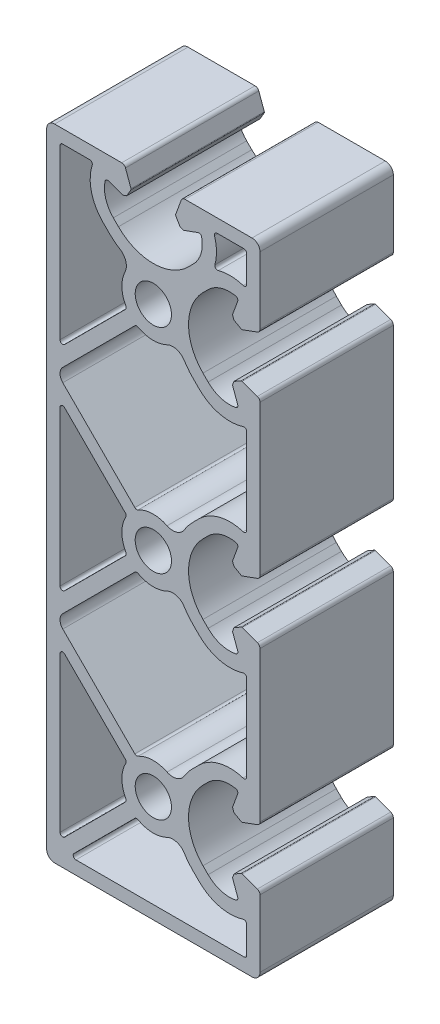
from build123d import *

# Parameters (mm, degrees)
SK_MAIN_EXTRUSION_R  = 3.4
MAIN_EXTRUSION_DEPTH = 25


with BuildPart() as part:
    # Sk Main Extrusion → Main Extrusion (new body)
    with BuildSketch(Plane.XY):
        with BuildLine():
            Line((16.671180212, 4.190076845), (19.506515107, 5.222054351))
            ThreePointArc((19.506515107, 5.222054351), (19.864364033, 5.496641489), (20, 5.926823816))
            Line((20, 5.926823816), (20, 34.073176184))
            ThreePointArc((20, 34.073176184), (19.864364033, 34.503358511), (19.506515107, 34.777945649))
            Line((19.506515107, 34.777945649), (16.671180212, 35.809923155))
            ThreePointArc((16.671180212, 35.809923155), (16.563886241, 35.824048675), (16.460675177, 35.791506351))
            Line((16.460675177, 35.791506351), (15.111296024, 35.012441934))
            Line((15.111296024, 35.012441934), (14.845251581, 34.281490834))
            Line((14.845251581, 34.281490834), (15.81984631, 31.603813821))
            ThreePointArc((15.81984631, 31.603813821), (15.786489799, 31.188925388), (15.450654467, 30.943039849))
            ThreePointArc((15.450654467, 30.943039849), (12.665882372, 31.066566987), (10.272684887, 32.495839661))
            Line((10.272684887, 32.495839661), (9.309262274, 33.459262274))
            ThreePointArc((9.309262274, 33.459262274), (6.6, 40), (9.309262274, 46.540737726))
            Line((9.309262274, 46.540737726), (10.272684887, 47.504160339))
            ThreePointArc((10.272684887, 47.504160339), (12.665882372, 48.933433013), (15.450654467, 49.056960151))
            ThreePointArc((15.450654467, 49.056960151), (15.786489799, 48.811074612), (15.81984631, 48.396186179))
            Line((15.81984631, 48.396186179), (14.845251581, 45.718509166))
            Line((14.845251581, 45.718509166), (15.111296024, 44.987558066))
            Line((15.111296024, 44.987558066), (16.460675177, 44.208493649))
            ThreePointArc((16.460675177, 44.208493649), (16.563886241, 44.175951325), (16.671180212, 44.190076845))
            Line((16.671180212, 44.190076845), (19.506515107, 45.222054351))
            ThreePointArc((19.506515107, 45.222054351), (19.864364033, 45.496641489), (20, 45.926823816))
            Line((20, 45.926823816), (20, 58.5))
            ThreePointArc((20, 58.5), (19.560660172, 59.560660172), (18.5, 60))
            Line((18.5, 60), (5.926823816, 60))
            ThreePointArc((5.926823816, 60), (5.496641489, 59.864364033), (5.222054351, 59.506515107))
            Line((5.222054351, 59.506515107), (4.190076845, 56.671180212))
            ThreePointArc((4.190076845, 56.671180212), (4.175951325, 56.563886241), (4.208493649, 56.460675177))
            Line((4.208493649, 56.460675177), (4.987558066, 55.111296024))
            Line((4.987558066, 55.111296024), (5.718509166, 54.845251581))
            Line((5.718509166, 54.845251581), (8.396186179, 55.81984631))
            ThreePointArc((8.396186179, 55.81984631), (8.811074612, 55.786489799), (9.056960151, 55.450654467))
            ThreePointArc((9.056960151, 55.450654467), (8.933433013, 52.665882372), (7.504160339, 50.272684887))
            Line((7.504160339, 50.272684887), (6.540737726, 49.309262274))
            ThreePointArc((6.540737726, 49.309262274), (0, 46.6), (-6.540737726, 49.309262274))
            Line((-6.540737726, 49.309262274), (-7.504160339, 50.272684887))
            ThreePointArc((-7.504160339, 50.272684887), (-8.933433013, 52.665882372), (-9.056960151, 55.450654467))
            ThreePointArc((-9.056960151, 55.450654467), (-8.811074612, 55.786489799), (-8.396186179, 55.81984631))
            Line((-8.396186179, 55.81984631), (-5.718509166, 54.845251581))
            Line((-5.718509166, 54.845251581), (-4.987558066, 55.111296024))
            Line((-4.987558066, 55.111296024), (-4.208493649, 56.460675177))
            ThreePointArc((-4.208493649, 56.460675177), (-4.175951325, 56.563886241), (-4.190076845, 56.671180212))
            Line((-4.190076845, 56.671180212), (-5.222054351, 59.506515107))
            ThreePointArc((-5.222054351, 59.506515107), (-5.496641489, 59.864364033), (-5.926823816, 60))
            Line((-5.926823816, 60), (-18.5, 60))
            ThreePointArc((-18.5, 60), (-19.560660172, 59.560660172), (-20, 58.5))
            Line((-20, 58.5), (-20, -58.5))
            ThreePointArc((-20, -58.5), (-19.560660172, -59.560660172), (-18.5, -60))
            Line((-18.5, -60), (18.5, -60))
            ThreePointArc((18.5, -60), (19.560660172, -59.560660172), (20, -58.5))
            Line((20, -58.5), (20, -45.926823816))
            ThreePointArc((20, -45.926823816), (19.864364033, -45.496641489), (19.506515107, -45.222054351))
            Line((19.506515107, -45.222054351), (16.671180212, -44.190076845))
            ThreePointArc((16.671180212, -44.190076845), (16.563886241, -44.175951325), (16.460675177, -44.208493649))
            Line((16.460675177, -44.208493649), (15.111296024, -44.987558066))
            Line((15.111296024, -44.987558066), (14.845251581, -45.718509166))
            Line((14.845251581, -45.718509166), (15.81984631, -48.396186179))
            ThreePointArc((15.81984631, -48.396186179), (15.786489799, -48.811074612), (15.450654467, -49.056960151))
            ThreePointArc((15.450654467, -49.056960151), (12.665882372, -48.933433013), (10.272684887, -47.504160339))
            Line((10.272684887, -47.504160339), (9.309262274, -46.540737726))
            ThreePointArc((9.309262274, -46.540737726), (6.6, -40), (9.309262274, -33.459262274))
            Line((9.309262274, -33.459262274), (10.272684887, -32.495839661))
            ThreePointArc((10.272684887, -32.495839661), (12.665882372, -31.066566987), (15.450654467, -30.943039849))
            ThreePointArc((15.450654467, -30.943039849), (15.786489799, -31.188925388), (15.81984631, -31.603813821))
            Line((15.81984631, -31.603813821), (14.845251581, -34.281490834))
            Line((14.845251581, -34.281490834), (15.111296024, -35.012441934))
            Line((15.111296024, -35.012441934), (16.460675177, -35.791506351))
            ThreePointArc((16.460675177, -35.791506351), (16.563886241, -35.824048675), (16.671180212, -35.809923155))
            Line((16.671180212, -35.809923155), (19.506515107, -34.777945649))
            ThreePointArc((19.506515107, -34.777945649), (19.864364033, -34.503358511), (20, -34.073176184))
            Line((20, -34.073176184), (20, -5.926823816))
            ThreePointArc((20, -5.926823816), (19.864364033, -5.496641489), (19.506515107, -5.222054351))
            Line((19.506515107, -5.222054351), (16.671180212, -4.190076845))
            ThreePointArc((16.671180212, -4.190076845), (16.563886241, -4.175951325), (16.460675177, -4.208493649))
            Line((16.460675177, -4.208493649), (15.111296024, -4.987558066))
            Line((15.111296024, -4.987558066), (14.845251581, -5.718509166))
            Line((14.845251581, -5.718509166), (15.81984631, -8.396186179))
            ThreePointArc((15.81984631, -8.396186179), (15.786489799, -8.811074612), (15.450654467, -9.056960151))
            ThreePointArc((15.450654467, -9.056960151), (12.665882372, -8.933433013), (10.272684887, -7.504160339))
            Line((10.272684887, -7.504160339), (9.309262274, -6.540737726))
            ThreePointArc((9.309262274, -6.540737726), (6.6, 0), (9.309262274, 6.540737726))
            Line((9.309262274, 6.540737726), (10.272684887, 7.504160339))
            ThreePointArc((10.272684887, 7.504160339), (12.665882372, 8.933433013), (15.450654467, 9.056960151))
            ThreePointArc((15.450654467, 9.056960151), (15.786489799, 8.811074612), (15.81984631, 8.396186179))
            Line((15.81984631, 8.396186179), (14.845251581, 5.718509166))
            Line((14.845251581, 5.718509166), (15.111296024, 4.987558066))
            Line((15.111296024, 4.987558066), (16.460675177, 4.208493649))
            ThreePointArc((16.460675177, 4.208493649), (16.563886241, 4.175951325), (16.671180212, 4.190076845))
        make_face()
        with Locations((0, -40)):
            Circle(SK_MAIN_EXTRUSION_R, mode=Mode.SUBTRACT)
        with Locations((0, 40)):
            Circle(SK_MAIN_EXTRUSION_R, mode=Mode.SUBTRACT)
        Circle(SK_MAIN_EXTRUSION_R, mode=Mode.SUBTRACT)
        with BuildLine():
            Line((-17.5, 57), (-17.5, 25.474873734))
            ThreePointArc((-17.5, 25.474873734), (-17.191341716, 25.012933968), (-16.646446609, 25.121320344))
            Line((-16.646446609, 25.121320344), (-5.236899672, 36.530867281))
            ThreePointArc((-5.236899672, 36.530867281), (-5.095239754, 36.81540054), (-5.153698917, 37.127825306))
            ThreePointArc((-5.153698917, 37.127825306), (-5.897648575, 39.833442852), (-5.307583096, 42.576734694))
            ThreePointArc((-5.307583096, 42.576734694), (-5.153883821, 44.359333373), (-6.230846881, 45.788120301))
            ThreePointArc((-6.230846881, 45.788120301), (-7.316529108, 46.555931161), (-8.308504679, 47.441495321))
            Line((-8.308504679, 47.441495321), (-9.444282589, 48.577273231))
            ThreePointArc((-9.444282589, 48.577273231), (-11.611987193, 52.430514315), (-11.464011904, 56.849169473))
            ThreePointArc((-11.464011904, 56.849169473), (-11.537349181, 57.295452819), (-11.940719521, 57.5))
            Line((-11.940719521, 57.5), (-17, 57.5))
            ThreePointArc((-17, 57.5), (-17.353553391, 57.353553391), (-17.5, 57))
        make_face(mode=Mode.SUBTRACT)
        with BuildLine():
            Line((-3.469132719, 34.763100328), (-16.982233047, 21.25))
            ThreePointArc((-16.982233047, 21.25), (-17.5, 20), (-16.982233047, 18.75))
            Line((-16.982233047, 18.75), (-3.469132719, 5.236899672))
            ThreePointArc((-3.469132719, 5.236899672), (-3.18459946, 5.095239754), (-2.872174694, 5.153698917))
            ThreePointArc((-2.872174694, 5.153698917), (-0.166557148, 5.897648575), (2.576734694, 5.307583096))
            ThreePointArc((2.576734694, 5.307583096), (4.359333373, 5.153883821), (5.788120301, 6.230846881))
            ThreePointArc((5.788120301, 6.230846881), (6.555931161, 7.316529108), (7.441495321, 8.308504679))
            Line((7.441495321, 8.308504679), (8.577273231, 9.444282589))
            ThreePointArc((8.577273231, 9.444282589), (12.430514315, 11.611987193), (16.849169473, 11.464011904))
            ThreePointArc((16.849169473, 11.464011904), (17.295452819, 11.537349181), (17.5, 11.940719521))
            Line((17.5, 11.940719521), (17.5, 28.059280479))
            ThreePointArc((17.5, 28.059280479), (17.295452819, 28.462650819), (16.849169473, 28.535988096))
            ThreePointArc((16.849169473, 28.535988096), (12.430514315, 28.388012807), (8.577273231, 30.555717411))
            Line((8.577273231, 30.555717411), (7.441495321, 31.691495321))
            ThreePointArc((7.441495321, 31.691495321), (6.555931161, 32.683470892), (5.788120301, 33.769153119))
            ThreePointArc((5.788120301, 33.769153119), (4.359333373, 34.846116179), (2.576734694, 34.692416904))
            ThreePointArc((2.576734694, 34.692416904), (-0.166557148, 34.102351425), (-2.872174694, 34.846301083))
            ThreePointArc((-2.872174694, 34.846301083), (-3.18459946, 34.904760246), (-3.469132719, 34.763100328))
        make_face(mode=Mode.SUBTRACT)
        with BuildLine():
            Line((-17.5, 14.525126266), (-17.5, -14.525126266))
            ThreePointArc((-17.5, -14.525126266), (-17.191341716, -14.987066032), (-16.646446609, -14.878679656))
            Line((-16.646446609, -14.878679656), (-5.236899672, -3.469132719))
            ThreePointArc((-5.236899672, -3.469132719), (-5.095239754, -3.18459946), (-5.153698917, -2.872174694))
            ThreePointArc((-5.153698917, -2.872174694), (-5.9, 0), (-5.153698917, 2.872174694))
            ThreePointArc((-5.153698917, 2.872174694), (-5.095239754, 3.18459946), (-5.236899672, 3.469132719))
            Line((-5.236899672, 3.469132719), (-16.646446609, 14.878679656))
            ThreePointArc((-16.646446609, 14.878679656), (-17.191341716, 14.987066032), (-17.5, 14.525126266))
        make_face(mode=Mode.SUBTRACT)
        with BuildLine():
            Line((-16.982233047, -21.25), (-3.469132719, -34.763100328))
            ThreePointArc((-3.469132719, -34.763100328), (-3.18459946, -34.904760246), (-2.872174694, -34.846301083))
            ThreePointArc((-2.872174694, -34.846301083), (-0.166557148, -34.102351425), (2.576734694, -34.692416904))
            ThreePointArc((2.576734694, -34.692416904), (4.359333373, -34.846116179), (5.788120301, -33.769153119))
            ThreePointArc((5.788120301, -33.769153119), (6.555931161, -32.683470892), (7.441495321, -31.691495321))
            Line((7.441495321, -31.691495321), (8.577273231, -30.555717411))
            ThreePointArc((8.577273231, -30.555717411), (12.430514315, -28.388012807), (16.849169473, -28.535988096))
            ThreePointArc((16.849169473, -28.535988096), (17.295452819, -28.462650819), (17.5, -28.059280479))
            Line((17.5, -28.059280479), (17.5, -11.940719521))
            ThreePointArc((17.5, -11.940719521), (17.295452819, -11.537349181), (16.849169473, -11.464011904))
            ThreePointArc((16.849169473, -11.464011904), (12.430514315, -11.611987193), (8.577273231, -9.444282589))
            Line((8.577273231, -9.444282589), (7.441495321, -8.308504679))
            ThreePointArc((7.441495321, -8.308504679), (6.555931161, -7.316529108), (5.788120301, -6.230846881))
            ThreePointArc((5.788120301, -6.230846881), (4.359333373, -5.153883821), (2.576734694, -5.307583096))
            ThreePointArc((2.576734694, -5.307583096), (-0.166557148, -5.897648575), (-2.872174694, -5.153698917))
            ThreePointArc((-2.872174694, -5.153698917), (-3.18459946, -5.095239754), (-3.469132719, -5.236899672))
            Line((-3.469132719, -5.236899672), (-16.982233047, -18.75))
            ThreePointArc((-16.982233047, -18.75), (-17.5, -20), (-16.982233047, -21.25))
        make_face(mode=Mode.SUBTRACT)
        with BuildLine():
            Line((-3.469132719, -45.236899672), (-14.878679656, -56.646446609))
            ThreePointArc((-14.878679656, -56.646446609), (-14.987066032, -57.191341716), (-14.525126266, -57.5))
            Line((-14.525126266, -57.5), (17, -57.5))
            ThreePointArc((17, -57.5), (17.353553391, -57.353553391), (17.5, -57))
            Line((17.5, -57), (17.5, -51.940719521))
            ThreePointArc((17.5, -51.940719521), (17.295452819, -51.537349181), (16.849169473, -51.464011904))
            ThreePointArc((16.849169473, -51.464011904), (12.430514315, -51.611987193), (8.577273231, -49.444282589))
            Line((8.577273231, -49.444282589), (7.441495321, -48.308504679))
            ThreePointArc((7.441495321, -48.308504679), (6.555931161, -47.316529108), (5.788120301, -46.230846881))
            ThreePointArc((5.788120301, -46.230846881), (4.359333373, -45.153883821), (2.576734694, -45.307583096))
            ThreePointArc((2.576734694, -45.307583096), (-0.166557148, -45.897648575), (-2.872174694, -45.153698917))
            ThreePointArc((-2.872174694, -45.153698917), (-3.18459946, -45.095239754), (-3.469132719, -45.236899672))
        make_face(mode=Mode.SUBTRACT)
        with BuildLine():
            Line((-17.5, -25.474873734), (-17.5, -54.525126266))
            ThreePointArc((-17.5, -54.525126266), (-17.191341716, -54.987066032), (-16.646446609, -54.878679656))
            Line((-16.646446609, -54.878679656), (-5.236899672, -43.469132719))
            ThreePointArc((-5.236899672, -43.469132719), (-5.095239754, -43.18459946), (-5.153698917, -42.872174694))
            ThreePointArc((-5.153698917, -42.872174694), (-5.9, -40), (-5.153698917, -37.127825306))
            ThreePointArc((-5.153698917, -37.127825306), (-5.095239754, -36.81540054), (-5.236899672, -36.530867281))
            Line((-5.236899672, -36.530867281), (-16.646446609, -25.121320344))
            ThreePointArc((-16.646446609, -25.121320344), (-17.191341716, -25.012933968), (-17.5, -25.474873734))
        make_face(mode=Mode.SUBTRACT)
        with BuildLine():
            Line((17.5, 51.940719521), (17.5, 57))
            ThreePointArc((17.5, 57), (17.353553391, 57.353553391), (17, 57.5))
            Line((17, 57.5), (11.940719521, 57.5))
            ThreePointArc((11.940719521, 57.5), (11.537349181, 57.295452819), (11.464011904, 56.849169473))
            ThreePointArc((11.464011904, 56.849169473), (11.844928721, 54.508523804), (11.540116235, 52.156756572))
            ThreePointArc((11.540116235, 52.156756572), (11.66791097, 51.66791097), (12.156756572, 51.540116235))
            ThreePointArc((12.156756572, 51.540116235), (14.508523804, 51.844928721), (16.849169473, 51.464011904))
            ThreePointArc((16.849169473, 51.464011904), (17.295452819, 51.537349181), (17.5, 51.940719521))
        make_face(mode=Mode.SUBTRACT)
    extrude(amount=-MAIN_EXTRUSION_DEPTH)


solid = part.part
